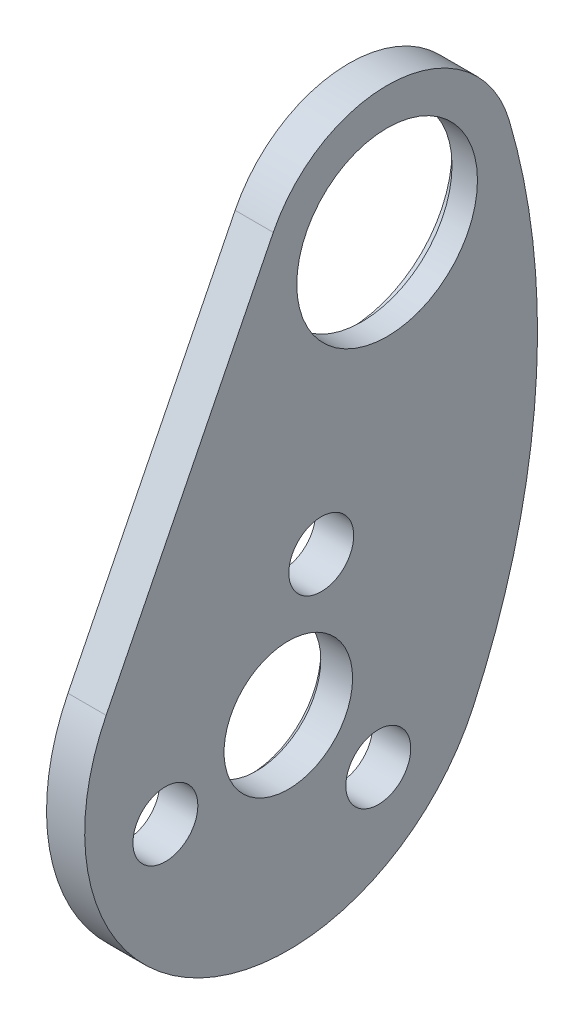
from build123d import *

# Parameters (mm, degrees)
EXTRUDE_1_DEPTH          = 3
SKETCH_2_R               = 7.1
SKETCH_2_R_2             = 5.05
CUT_EXTRUDE_1_DEPTH      = 10
SKETCH_3_R               = 2.55
CUT_EXTRUDE_2_DEPTH      = 10
PATTERN_CIRCULAR_1_COUNT = 3
CHAMFER_1_SIZE           = 0.5
SKETCH_4_R               = 8.1
CUT_EXTRUDE_3_DEPTH      = 1


with BuildPart() as part:
    # 草图1 → 凸台-拉伸1 (new body)
    with BuildSketch(Plane(origin=(0, 0, 0), x_dir=(0, 0, -1), z_dir=(1, 0, 0))):
        with BuildLine():
            ThreePointArc((6.766526321, -35.674580026), (11.667792815, -16.687604516), (9.596471541, 2.812069339))
            ThreePointArc((9.596471541, 2.812069339), (0.889352151, 9.960374127), (-8.946463525, 4.467750037))
            Line((-8.946463525, 4.467750037), (-22.078912993, -21.829374729))
            ThreePointArc((-22.078912993, -21.829374729), (-14.688022315, -43.402261843), (6.766526321, -35.674580026))
        make_face()
    extrude(amount=EXTRUDE_1_DEPTH)

    # 草图2 → 切除-拉伸1 (cut)
    with BuildSketch(Plane.ZY):
        Circle(SKETCH_2_R)
        with Locations((7.764571353, -28.977774789)):
            Circle(SKETCH_2_R_2)
    extrude(amount=-CUT_EXTRUDE_1_DEPTH, mode=Mode.SUBTRACT)

    # 草图3 → 切除-拉伸2 (cut)
    with BuildSketch(Plane.ZY):
        with Locations((5.176380902, -19.318516526)):
            Circle(SKETCH_3_R)
    cut_extrude_2 = extrude(amount=-CUT_EXTRUDE_2_DEPTH, mode=Mode.SUBTRACT)

    # 阵列(圆周)1: 切除-拉伸2 ×3 about axis
    pattern_circular_1_axis = Axis((0, -28.977774789, 7.764571353), (1, 0, 0))
    for i in range(1, PATTERN_CIRCULAR_1_COUNT):
        add(cut_extrude_2.rotate(pattern_circular_1_axis, i * 360 / PATTERN_CIRCULAR_1_COUNT), mode=Mode.SUBTRACT)

    # 倒角1
    chamfer_1_edges = [part.edges().sort_by_distance(p)[0] for p in [
        (0, -28.977774789, 2.714571353),
    ]]
    chamfer(chamfer_1_edges, length=CHAMFER_1_SIZE)

    # 草图4 → 切除-拉伸3 (cut)
    with BuildSketch(Plane.ZY):
        Circle(SKETCH_4_R)
    extrude(amount=-CUT_EXTRUDE_3_DEPTH, mode=Mode.SUBTRACT)


solid = part.part
